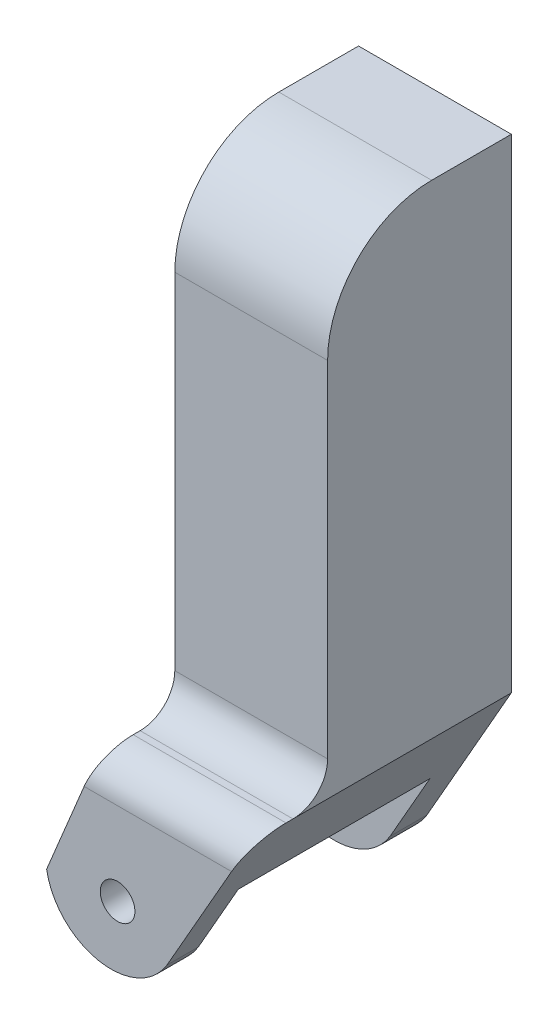
from build123d import *

# Parameters (mm, degrees)
EXTRUDE_1_DEPTH     = 53
EXTRUDE_2_DEPTH     = 22
FILLET_2_R          = 10
FILLET_3_R          = 10
SKETCH_3_W          = 55.304366744
SKETCH_3_H          = 61.895042574
CUT_EXTRUDE_1_DEPTH = 56
SKETCH_4_R          = 5
CUT_EXTRUDE_2_DEPTH = 75
SKETCH_5_R          = 5
CUT_EXTRUDE_3_DEPTH = 10
FILLET_4_R          = 30


with BuildPart() as part:
    # Эскиз1 → Бобышка-Вытянуть1 (new body)
    with BuildSketch(Plane.XY):
        with BuildLine():
            Line((7.580184654, -59.799234496), (-16.79145183, -102.52734615))
            ThreePointArc((-16.79145183, -102.52734615), (-36.438294134, -111.229048288), (-51.465460174, -95.869936548))
            Line((-51.465460174, -95.869936548), (-36.497185373, -59.799234496))
            Line((-36.497185373, -59.799234496), (-36.497185373, 79.732312661))
            Line((-36.497185373, 79.732312661), (7.580184654, 79.732312661))
            Line((7.580184654, 79.732312661), (7.580184654, -59.799234496))
        make_face()
    extrude(amount=EXTRUDE_1_DEPTH)

    # Эскиз2 → Бобышка-Вытянуть2 (add)
    with BuildSketch(Plane.XY.offset(53)):
        with BuildLine():
            Line((-36.497185373, -59.799234496), (7.580184654, -59.799234496))
            Line((7.580184654, -59.799234496), (-16.79145183, -102.52734615))
            ThreePointArc((-16.79145183, -102.52734615), (-36.438294134, -111.229048288), (-51.465460174, -95.869936548))
            Line((-51.465460174, -95.869936548), (-36.497185373, -59.799234496))
        make_face()
    extrude(amount=EXTRUDE_2_DEPTH)

    # Скругление2
    fillet_2_edges = [part.edges().sort_by_distance(p)[0] for p in [
        (-14.458500359, -59.799234496, 53),
    ]]
    fillet(fillet_2_edges, radius=FILLET_2_R)

    # Скругление3
    fillet_3_edges = [part.edges().sort_by_distance(p)[0] for p in [
        (-14.458500359, -59.799234496, 75),
    ]]
    fillet(fillet_3_edges, radius=FILLET_3_R)

    # Эскиз3 → Вырез-Вытянуть1 (cut)
    with BuildSketch(Plane(origin=(-9.966103605, 4.135638315, 0), x_dir=(0, 0, 1), z_dir=(-0.923632182, 0.383280045, 0))):
        with Locations((38.275019494, -109.025889751)):
            Rectangle(SKETCH_3_W, SKETCH_3_H)
    extrude(amount=-CUT_EXTRUDE_1_DEPTH, mode=Mode.SUBTRACT)

    # Эскиз4 → Вырез-Вытянуть2 (cut)
    with BuildSketch(Plane.XY.offset(75)):
        with Locations((-31.007416938, -93.698436978)):
            Circle(SKETCH_4_R)
    extrude(amount=-CUT_EXTRUDE_2_DEPTH, mode=Mode.SUBTRACT)

    # Эскиз5 → Вырез-Вытянуть3 (cut)
    with BuildSketch(Plane(origin=(0, 0, 0), x_dir=(-1, 0, 0), z_dir=(0, 0, -1))):
        with Locations((15.173432646, 61.131642173)):
            Circle(SKETCH_5_R)
    extrude(amount=-CUT_EXTRUDE_3_DEPTH, mode=Mode.SUBTRACT)

    # Скругление4
    fillet_4_edges = [part.edges().sort_by_distance(p)[0] for p in [
        (-14.458500359, 79.732312661, 53),
    ]]
    fillet(fillet_4_edges, radius=FILLET_4_R)


solid = part.part
